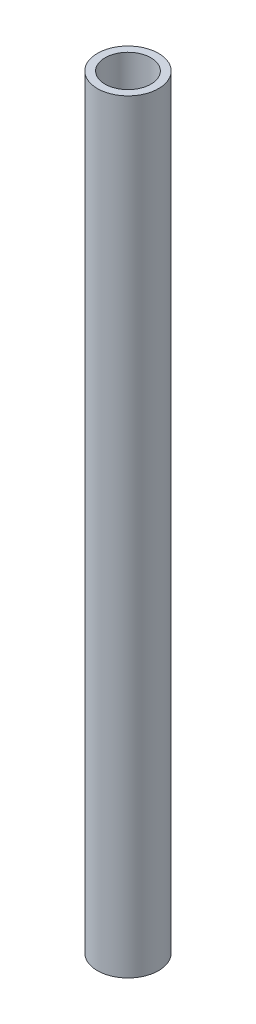
from build123d import *

# Parameters (mm, degrees)
SKETCH_1_R      = 10
SKETCH_1_R_2    = 7.5
EXTRUDE_1_DEPTH = 250


with BuildPart() as part:
    # 스케치1 → 보스-돌출1 (new body)
    with BuildSketch(Plane(origin=(0, 0, 0), x_dir=(1, 0, 0), z_dir=(0, 1, 0))):
        Circle(SKETCH_1_R)
        Circle(SKETCH_1_R_2, mode=Mode.SUBTRACT)
    extrude(amount=EXTRUDE_1_DEPTH)


solid = part.part
